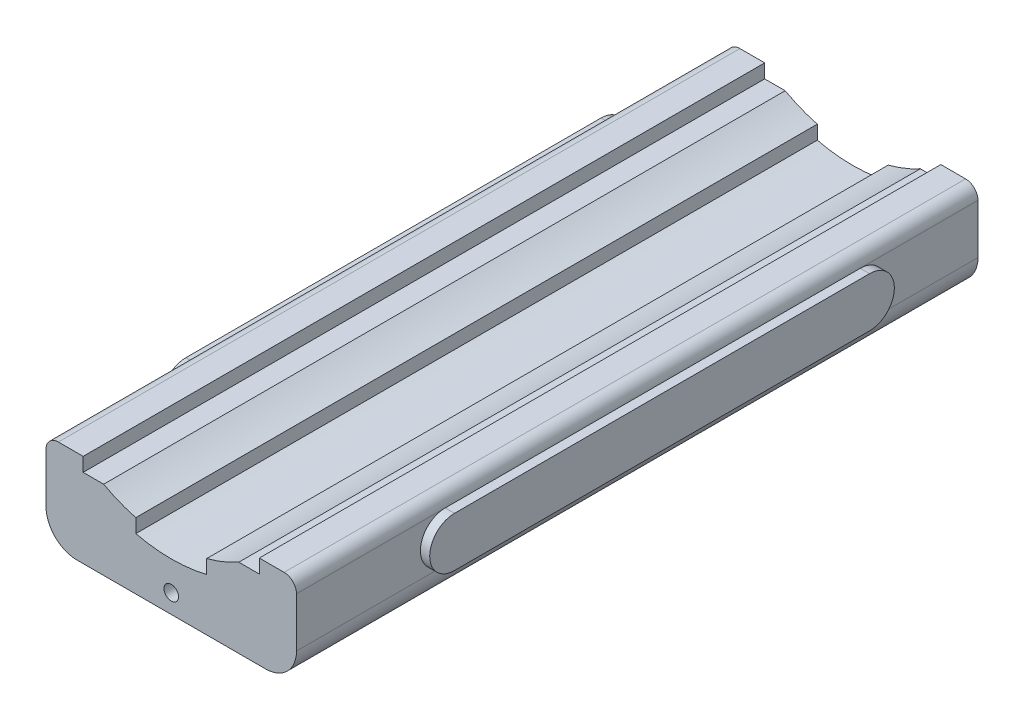
from build123d import *

# Parameters (mm, degrees)
BOSS_EXTRUDE1_DEPTH = 220
FILLET1_R           = 4
FILLET2_R           = 10
SKETCH6_W           = 150
SKETCH6_H           = 16
BOSS_EXTRUDE2_DEPTH = 3
SKETCH7_W           = 150
SKETCH7_H           = 16
BOSS_EXTRUDE3_DEPTH = 3
CUT_EXTRUDE1_DEPTH  = 3
CUT_EXTRUDE2_DEPTH  = 3
SKETCH10_R          = 2.341915658
CUT_EXTRUDE3_DEPTH  = 5
SCALE1_SCALE        = 15.6
SCALE2_SCALE        = 0.5


with BuildPart() as part:
    # Sketch1 → Boss-Extrude1 (new body)
    with BuildSketch(Plane.XY):
        with BuildLine():
            ThreePointArc((39.877280439, -8.639636697), (45.189316192, -6.882935474), (50.242300545, -4.480629882))
            Line((50.242300545, -4.480629882), (56.863188539, -4.480629882))
            Line((56.863188539, -4.480629882), (56.863188539, 0))
            Line((56.863188539, 0), (68.863188539, 0))
            Line((68.863188539, 0), (68.863188539, -30))
            Line((68.863188539, -30), (-12, -30))
            Line((-12, -30), (-12, 0))
            Line((-12, 0), (0, 0))
            Line((0, 0), (0, -4.480629882))
            Line((0, -4.480629882), (6.620887994, -4.480629882))
            ThreePointArc((6.620887994, -4.480629882), (11.673872347, -6.882935474), (16.9859081, -8.639636697))
            Line((16.9859081, -8.639636697), (16.9859081, -13.120266579))
            ThreePointArc((16.9859081, -13.120266579), (28.43159427, -14.466004542), (39.877280439, -13.120266579))
            Line((39.877280439, -13.120266579), (39.877280439, -8.639636697))
        make_face()
    extrude(amount=BOSS_EXTRUDE1_DEPTH)

    # Fillet1
    fillet1_edges = [part.edges().sort_by_distance(p)[0] for p in [
        (68.863188539, 0, 110),
        (-12, 0, 110),
    ]]
    fillet(fillet1_edges, radius=FILLET1_R)

    # Fillet2
    fillet2_edges = [part.edges().sort_by_distance(p)[0] for p in [
        (68.863188539, -30, 110),
        (-12, -30, 110),
    ]]
    fillet(fillet2_edges, radius=FILLET2_R)

    # Sketch6 → Boss-Extrude2 (add)
    with BuildSketch(Plane(origin=(68.863188539, 0, 0), x_dir=(0, 0, -1), z_dir=(1, 0, 0))):
        with Locations((-105, -12)):
            Rectangle(SKETCH6_W, SKETCH6_H)
    extrude(amount=BOSS_EXTRUDE2_DEPTH)

    # Sketch7 → Boss-Extrude3 (add)
    with BuildSketch(Plane.ZY.offset(12)):
        with Locations((104.824258167, -12)):
            Rectangle(SKETCH7_W, SKETCH7_H)
    extrude(amount=BOSS_EXTRUDE3_DEPTH)

    # Sketch8 → Cut-Extrude1 (cut)
    with BuildSketch(Plane.ZY.offset(15)):
        with BuildLine():
            ThreePointArc((37.824258167, -20), (32.167403918, -17.656854249), (29.824258167, -12))
            Line((29.824258167, -12), (29.824258167, -20))
            Line((29.824258167, -20), (37.824258167, -20))
        make_face()
        with BuildLine():
            ThreePointArc((29.824258167, -12), (32.167403918, -6.343145751), (37.824258167, -4))
            Line((37.824258167, -4), (29.824258167, -4))
            Line((29.824258167, -4), (29.824258167, -12))
        make_face()
        with BuildLine():
            Line((179.824258167, -20), (179.824258167, -12))
            ThreePointArc((179.824258167, -12), (177.481112417, -17.656854249), (171.824258167, -20))
            Line((171.824258167, -20), (179.824258167, -20))
        make_face()
        with BuildLine():
            Line((179.824258167, -4), (171.824258167, -4))
            ThreePointArc((171.824258167, -4), (177.481112417, -6.343145751), (179.824258167, -12))
            Line((179.824258167, -12), (179.824258167, -4))
        make_face()
    extrude(amount=-CUT_EXTRUDE1_DEPTH, mode=Mode.SUBTRACT)

    # Sketch9 → Cut-Extrude2 (cut)
    with BuildSketch(Plane(origin=(71.863188539, 0, 0), x_dir=(0, 0, -1), z_dir=(1, 0, 0))):
        with BuildLine():
            ThreePointArc((-180, -12), (-177.656854249, -6.343145751), (-172, -4))
            Line((-172, -4), (-180, -4))
            Line((-180, -4), (-180, -12))
        make_face()
        with BuildLine():
            ThreePointArc((-172, -20), (-177.656854249, -17.656854249), (-180, -12))
            Line((-180, -12), (-180, -20))
            Line((-180, -20), (-172, -20))
        make_face()
        with BuildLine():
            Line((-30, -4), (-38, -4))
            ThreePointArc((-38, -4), (-32.343145751, -6.343145751), (-30, -12))
            Line((-30, -12), (-30, -4))
        make_face()
        with BuildLine():
            Line((-30, -20), (-30, -12))
            ThreePointArc((-30, -12), (-32.343145751, -17.656854249), (-38, -20))
            Line((-38, -20), (-30, -20))
        make_face()
    extrude(amount=-CUT_EXTRUDE2_DEPTH, mode=Mode.SUBTRACT)

    # Sketch10 → Cut-Extrude3 (cut)
    with BuildSketch(Plane.XY.offset(220)):
        with Locations((28.43159427, -23.894216735)):
            Circle(SKETCH10_R)
    extrude(amount=-CUT_EXTRUDE3_DEPTH, mode=Mode.SUBTRACT)


with BuildPart() as part_1:
    # Scale1: scaled about (28.43159427, -17.23906253, 109.80841841)
    add(part.part.scale(SCALE1_SCALE).moved(Location((-415.101276342, 251.690312938, -1603.202908786))))


with BuildPart() as part_2:
    # Scale2: scaled about (28.431594264, -17.23906253, 109.808418405)
    add(part_1.part.scale(SCALE2_SCALE).moved(Location((14.215797132, -8.619531265, 54.904209202))))


solid = part_2.part
